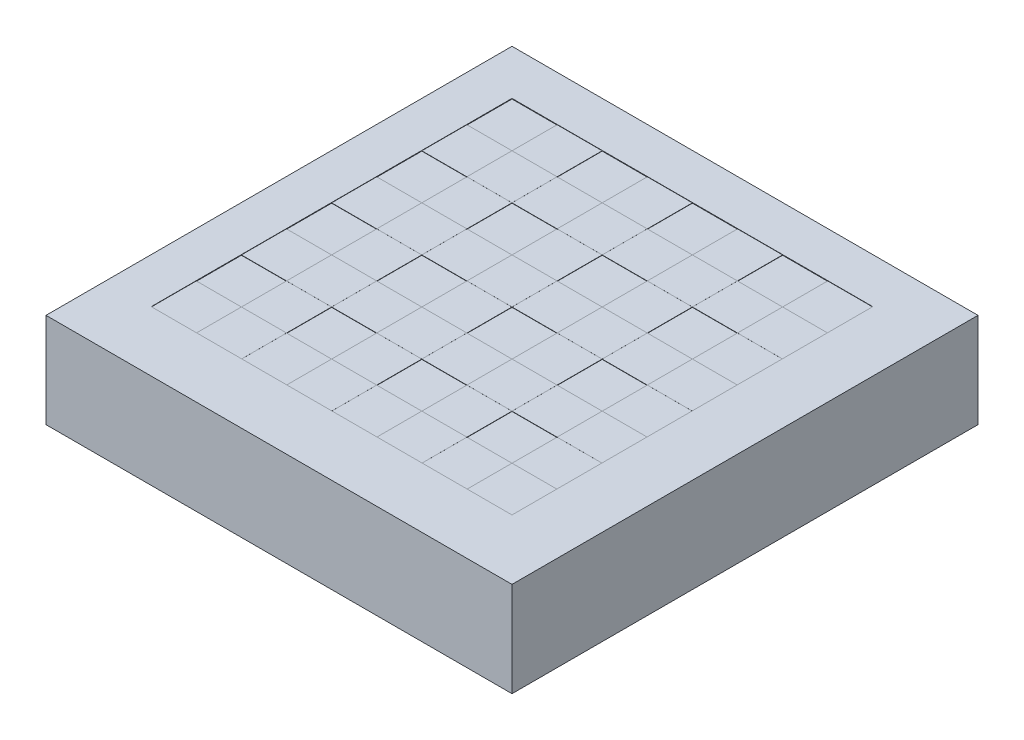
from build123d import *

# Parameters (mm, degrees)
SKETCH1_W                       = 393.7
SKETCH1_H                       = 393.7
BOSS_EXTRUDE1_DEPTH             = 80
ESQUISSE1_W                     = 304.8
ESQUISSE1_H                     = 304.8
ENL_V_MAT_EXTRU_1_DEPTH         = 0.254
ESQUISSE4_W                     = 38.1
ESQUISSE4_H                     = 38.1
ENL_V_MAT_EXTRU_2_DEPTH         = 0.254
R_P_TITION_LIN_AIRE1_COUNT      = 4
R_P_TITION_LIN_AIRE1_PITCH      = 76.2
R_P_TITION_LIN_AIRE1_COUNT_DIR2 = 4
R_P_TITION_LIN_AIRE1_PITCH_DIR2 = 76.2
ESQUISSE5_W                     = 38.1
ESQUISSE5_H                     = 38.1
BOSS_EXTRU_1_DEPTH              = 0.0254
R_P_TITION_LIN_AIRE2_COUNT      = 4
R_P_TITION_LIN_AIRE2_PITCH      = 76.2
R_P_TITION_LIN_AIRE2_COUNT_DIR2 = 4
R_P_TITION_LIN_AIRE2_PITCH_DIR2 = 76.2


with BuildPart() as part:
    # Sketch1 → Boss-Extrude1 (new body)
    with BuildSketch(Plane(origin=(0, 0, 0), x_dir=(1, 0, 0), z_dir=(0, 1, 0))):
        with Locations((196.85, -196.85)):
            Rectangle(SKETCH1_W, SKETCH1_H)
    extrude(amount=BOSS_EXTRUDE1_DEPTH)

    # Esquisse1 → Enlèv. mat.-Extru.1 (cut)
    with BuildSketch(Plane(origin=(0, 80, 0), x_dir=(1, 0, 0), z_dir=(0, 1, 0))):
        with Locations((190.5, -190.5)):
            Rectangle(ESQUISSE1_W, ESQUISSE1_H)
    extrude(amount=-ENL_V_MAT_EXTRU_1_DEPTH, mode=Mode.SUBTRACT)

    # Esquisse4 → Enlèv. mat.-Extru.2 (cut)
    with BuildSketch(Plane(origin=(0, 79.746, 0), x_dir=(1, 0, 0), z_dir=(0, 1, 0))):
        with Locations((57.15, -57.15)):
            Rectangle(ESQUISSE4_W, ESQUISSE4_H)
    enl_v_mat_extru_2 = extrude(amount=-ENL_V_MAT_EXTRU_2_DEPTH, mode=Mode.SUBTRACT)

    # Répétition linéaire1: Enl_v. mat.-Extru.2 4 × 4
    with Locations(*[(i * R_P_TITION_LIN_AIRE1_PITCH, 0, j * R_P_TITION_LIN_AIRE1_PITCH_DIR2) for i in range(R_P_TITION_LIN_AIRE1_COUNT) for j in range(R_P_TITION_LIN_AIRE1_COUNT_DIR2) if (i, j) != (0, 0)]):
        add(enl_v_mat_extru_2, mode=Mode.SUBTRACT)

    # Esquisse5 → Boss.-Extru.1 (add)
    with BuildSketch(Plane(origin=(0, 79.746, 0), x_dir=(1, 0, 0), z_dir=(0, 1, 0))):
        with Locations((95.25, -95.25)):
            Rectangle(ESQUISSE5_W, ESQUISSE5_H)
    boss_extru_1 = extrude(amount=BOSS_EXTRU_1_DEPTH)

    # Répétition linéaire2: Boss.-Extru.1 4 × 4
    with Locations(*[(j * R_P_TITION_LIN_AIRE2_PITCH_DIR2, 0, i * R_P_TITION_LIN_AIRE2_PITCH) for i in range(R_P_TITION_LIN_AIRE2_COUNT) for j in range(R_P_TITION_LIN_AIRE2_COUNT_DIR2) if (i, j) != (0, 0)]):
        add(boss_extru_1)


solid = part.part
